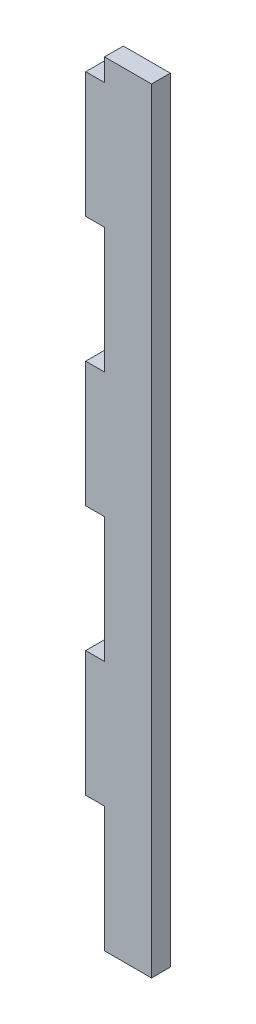
from build123d import *

# Parameters (mm, degrees)
BOSS_EXTRU_1_DEPTH = 6


with BuildPart() as part:
    # Esquisse1 → Boss.-Extru.1 (new body)
    with BuildSketch(Plane.XY):
        Polygon((15, 181.409908735), (15, -65.693798427), (0, -65.693798427), (0, -25.691976137), (-6, -25.691976137), (-6, 14.306809003), (0, 14.306809003), (0, 54.308631292), (-6, 54.308631292), (-6, 94.307416433), (0, 94.307416433), (0, 134.309238722), (-6, 134.309238722), (-6, 174.308023863), (0, 174.308023863), (0, 181.409908735), align=None)
    extrude(amount=-BOSS_EXTRU_1_DEPTH)


solid = part.part
